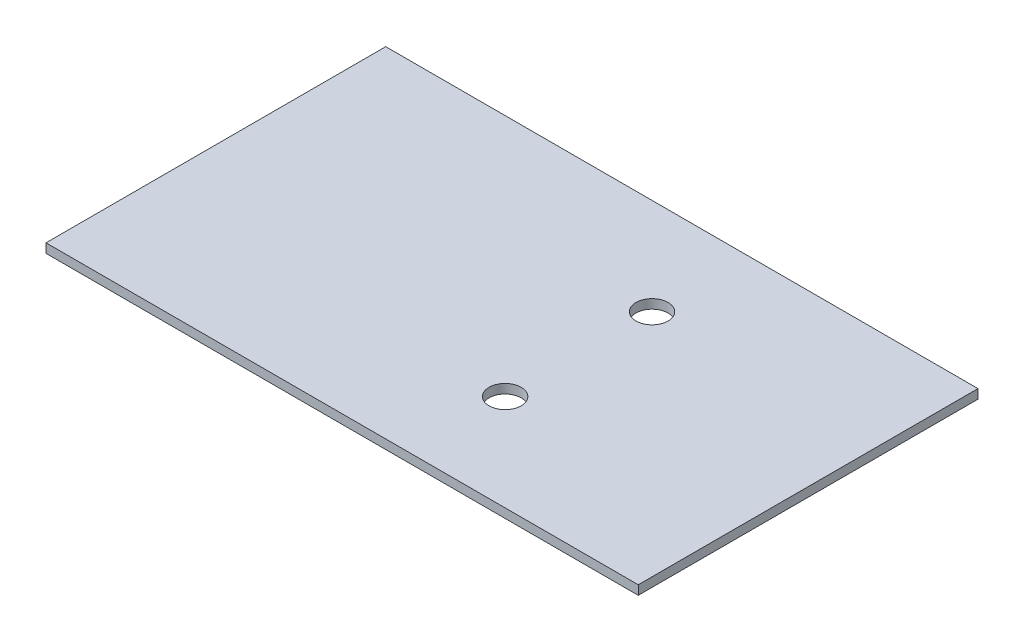
from build123d import *

# Parameters (mm, degrees)
SKETCH1_W           = 129
SKETCH1_H           = 74
BOSS_EXTRUDE1_DEPTH = 2
SKETCH2_R           = 3.5
CUT_EXTRUDE1_DEPTH  = 3


with BuildPart() as part:
    # Sketch1 → Boss-Extrude1 (new body)
    with BuildSketch(Plane(origin=(0, 0, 0), x_dir=(1, 0, 0), z_dir=(0, 1, 0))):
        with Locations((64.5, -37)):
            Rectangle(SKETCH1_W, SKETCH1_H)
    extrude(amount=BOSS_EXTRUDE1_DEPTH)

    # Sketch2 → Cut-Extrude1 (cut, through all)
    with BuildSketch(Plane.XZ):
        with Locations((79, 21)):
            Circle(SKETCH2_R)
        with Locations((79, 53)):
            Circle(SKETCH2_R)
    extrude(amount=-CUT_EXTRUDE1_DEPTH, mode=Mode.SUBTRACT)


solid = part.part
